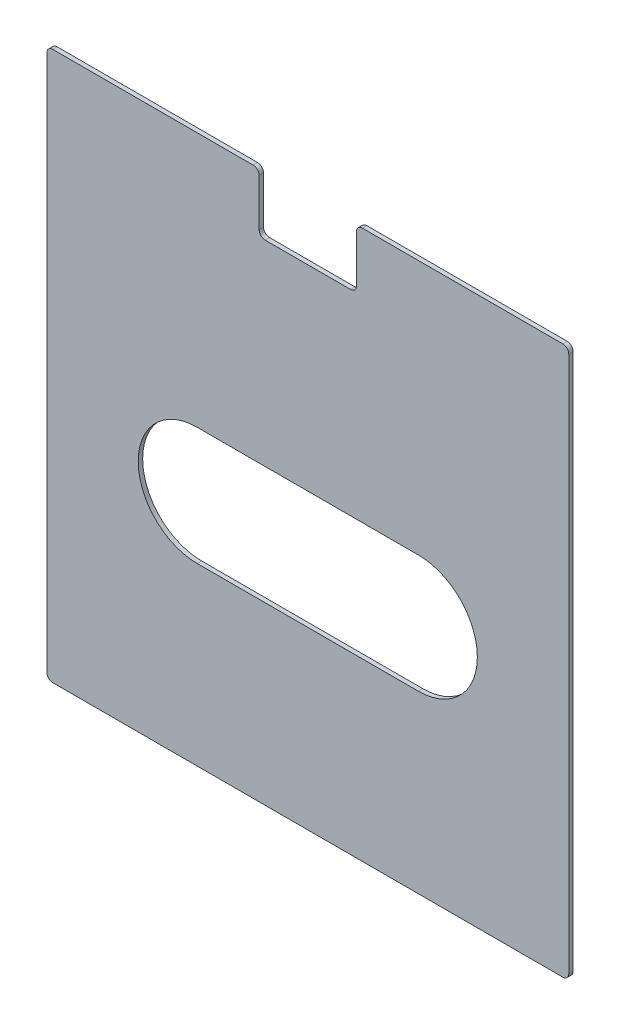
from build123d import *

# Parameters (mm, degrees)
BOSS_EXTRUDE1_DEPTH = 1.5
FILLET1_R           = 2
CUT_EXTRUDE1_DEPTH  = 10


with BuildPart() as part:
    # Sketch1 → Boss-Extrude1 (new body)
    with BuildSketch(Plane.XY):
        Polygon((0, 0), (177, 0), (177, 186), (105, 186), (105, 166), (72, 166), (72, 186), (0, 186), align=None)
    extrude(amount=BOSS_EXTRUDE1_DEPTH)

    # Fillet1
    fillet1_edges = [part.edges().sort_by_distance(p)[0] for p in [
        (0, 186, 0.75),
        (72, 186, 0.75),
        (72, 166, 0.75),
        (105, 166, 0.75),
        (105, 186, 0.75),
        (177, 186, 0.75),
        (177, 0, 0.75),
        (0, 0, 0.75),
    ]]
    fillet(fillet1_edges, radius=FILLET1_R)

    # Sketch2 → Cut-Extrude1 (cut)
    with BuildSketch(Plane(origin=(0, 0, 0), x_dir=(-1, 0, 0), z_dir=(0, 0, -1))):
        with BuildLine():
            Line((-126, 99.5), (-51, 99.5))
            ThreePointArc((-51, 99.5), (-31, 79.5), (-51, 59.5))
            Line((-51, 59.5), (-126, 59.5))
            ThreePointArc((-126, 59.5), (-146, 79.5), (-126, 99.5))
        make_face()
    extrude(amount=-CUT_EXTRUDE1_DEPTH, mode=Mode.SUBTRACT)


solid = part.part
